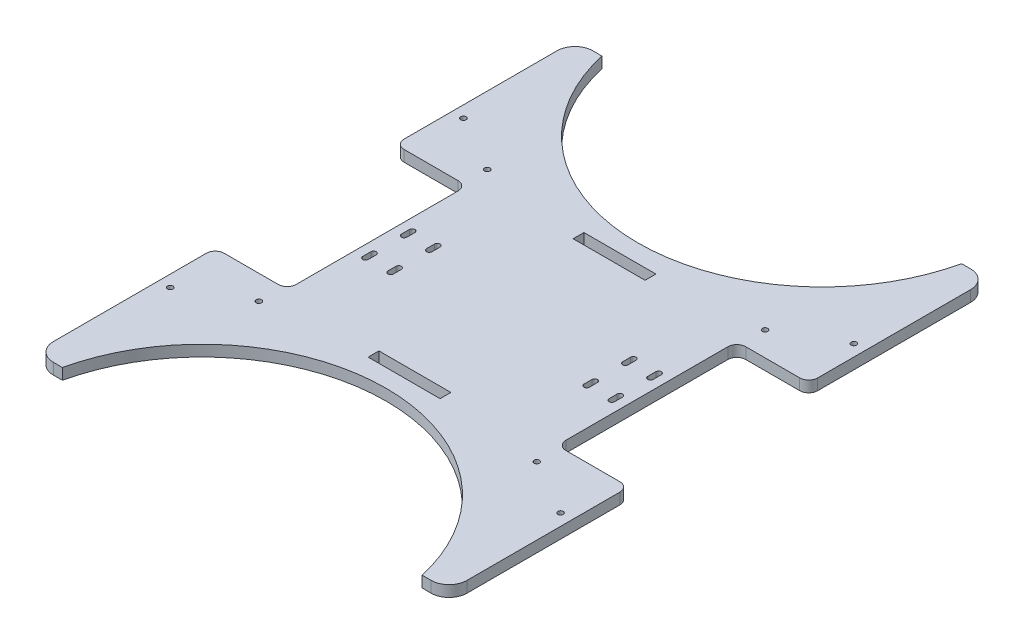
from build123d import *

# Parameters (mm, degrees)
EXTRUDE_1_DEPTH          = 6.18
CUT_EXTRUDE_1_DEPTH      = 7.18
FILLET_2_R               = 5
FILLET_3_R               = 5
FILLET_4_R               = 5
FILLET_5_R               = 5
SKETCH_4_W               = 40
SKETCH_4_H               = 6
SKETCH_4_R               = 1.5
CUT_EXTRUDE_2_DEPTH      = 7.18
CUT_EXTRUDE_9_DEPTH      = 1
CUT_EXTRUDE_9_DEPTH_BACK = 7.18


with BuildPart() as part:
    # 草图1 → 凸台-拉伸1 (new body)
    with BuildSketch(Plane(origin=(0, 0, 0), x_dir=(1, 0, 0), z_dir=(0, 1, 0))):
        with BuildLine():
            Line((18.586012984, 33.22179039), (228.586012984, 33.22179039))
            ThreePointArc((228.586012984, 33.22179039), (235.657080796, 30.292858202), (238.586012984, 23.22179039))
            Line((238.586012984, 23.22179039), (238.586012984, -256.77820961))
            ThreePointArc((238.586012984, -256.77820961), (235.657080796, -263.849277422), (228.586012984, -266.77820961))
            Line((228.586012984, -266.77820961), (18.586012984, -266.77820961))
            ThreePointArc((18.586012984, -266.77820961), (11.514945172, -263.849277422), (8.586012984, -256.77820961))
            Line((8.586012984, -256.77820961), (8.586012984, 23.22179039))
            ThreePointArc((8.586012984, 23.22179039), (11.514945172, 30.292858202), (18.586012984, 33.22179039))
        make_face()
    extrude(amount=EXTRUDE_1_DEPTH)

    # 草图2 → 切除-拉伸1 (cut, through all)
    with BuildSketch(Plane(origin=(0, 6.18, 0), x_dir=(1, 0, 0), z_dir=(0, 1, 0))):
        with BuildLine():
            Line((48.586012984, -161.77820961), (48.586012984, -71.77820961))
            ThreePointArc((48.586012984, -71.77820961), (47.12154689, -68.242675704), (43.586012984, -66.77820961))
            Line((43.586012984, -66.77820961), (8.586012984, -66.77820961))
            Line((8.586012984, -66.77820961), (8.586012984, -166.77820961))
            Line((8.586012984, -166.77820961), (43.586012984, -166.77820961))
            ThreePointArc((43.586012984, -166.77820961), (47.12154689, -165.313743516), (48.586012984, -161.77820961))
        make_face()
        with BuildLine():
            Line((56.586012984, -103.77820961), (56.586012984, -108.27820961))
            ThreePointArc((56.586012984, -108.27820961), (55.086012984, -109.77820961), (53.586012984, -108.27820961))
            Line((53.586012984, -108.27820961), (53.586012984, -103.77820961))
            ThreePointArc((53.586012984, -103.77820961), (55.086012984, -102.27820961), (56.586012984, -103.77820961))
        make_face()
        with BuildLine():
            Line((70.586012984, -103.77820961), (70.586012984, -108.27820961))
            ThreePointArc((70.586012984, -108.27820961), (69.086012984, -109.77820961), (67.586012984, -108.27820961))
            Line((67.586012984, -108.27820961), (67.586012984, -103.77820961))
            ThreePointArc((67.586012984, -103.77820961), (69.086012984, -102.27820961), (70.586012984, -103.77820961))
        make_face()
        with BuildLine():
            Line((70.586012984, -129.77820961), (70.586012984, -125.27820961))
            ThreePointArc((70.586012984, -125.27820961), (69.086012984, -123.77820961), (67.586012984, -125.27820961))
            Line((67.586012984, -125.27820961), (67.586012984, -129.77820961))
            ThreePointArc((67.586012984, -129.77820961), (69.086012984, -131.27820961), (70.586012984, -129.77820961))
        make_face()
        with BuildLine():
            Line((56.586012984, -129.77820961), (56.586012984, -125.27820961))
            ThreePointArc((56.586012984, -125.27820961), (55.086012984, -123.77820961), (53.586012984, -125.27820961))
            Line((53.586012984, -125.27820961), (53.586012984, -129.77820961))
            ThreePointArc((53.586012984, -129.77820961), (55.086012984, -131.27820961), (56.586012984, -129.77820961))
        make_face()
        with BuildLine():
            Line((176.586012984, -129.77820961), (176.586012984, -125.27820961))
            ThreePointArc((176.586012984, -125.27820961), (178.086012984, -123.77820961), (179.586012984, -125.27820961))
            Line((179.586012984, -125.27820961), (179.586012984, -129.77820961))
            ThreePointArc((179.586012984, -129.77820961), (178.086012984, -131.27820961), (176.586012984, -129.77820961))
        make_face()
        with BuildLine():
            Line((190.586012984, -129.77820961), (190.586012984, -125.27820961))
            ThreePointArc((190.586012984, -125.27820961), (192.086012984, -123.77820961), (193.586012984, -125.27820961))
            Line((193.586012984, -125.27820961), (193.586012984, -129.77820961))
            ThreePointArc((193.586012984, -129.77820961), (192.086012984, -131.27820961), (190.586012984, -129.77820961))
        make_face()
        with BuildLine():
            Line((190.586012984, -103.77820961), (190.586012984, -108.27820961))
            ThreePointArc((190.586012984, -108.27820961), (192.086012984, -109.77820961), (193.586012984, -108.27820961))
            Line((193.586012984, -108.27820961), (193.586012984, -103.77820961))
            ThreePointArc((193.586012984, -103.77820961), (192.086012984, -102.27820961), (190.586012984, -103.77820961))
        make_face()
        with BuildLine():
            Line((176.586012984, -103.77820961), (176.586012984, -108.27820961))
            ThreePointArc((176.586012984, -108.27820961), (178.086012984, -109.77820961), (179.586012984, -108.27820961))
            Line((179.586012984, -108.27820961), (179.586012984, -103.77820961))
            ThreePointArc((179.586012984, -103.77820961), (178.086012984, -102.27820961), (176.586012984, -103.77820961))
        make_face()
        with BuildLine():
            Line((198.586012984, -161.77820961), (198.586012984, -71.77820961))
            ThreePointArc((198.586012984, -71.77820961), (200.050479078, -68.242675704), (203.586012984, -66.77820961))
            Line((203.586012984, -66.77820961), (238.586012984, -66.77820961))
            Line((238.586012984, -66.77820961), (238.586012984, -166.77820961))
            Line((238.586012984, -166.77820961), (203.586012984, -166.77820961))
            ThreePointArc((203.586012984, -166.77820961), (200.050479078, -165.313743516), (198.586012984, -161.77820961))
        make_face()
    extrude(amount=-CUT_EXTRUDE_1_DEPTH, mode=Mode.SUBTRACT)

    # 圆角2
    fillet_2_edges = [part.edges().sort_by_distance(p)[0] for p in [
        (8.586012984, 3.09, 66.77820961),
    ]]
    fillet(fillet_2_edges, radius=FILLET_2_R)

    # 圆角3
    fillet_3_edges = [part.edges().sort_by_distance(p)[0] for p in [
        (8.586012984, 3.09, 166.77820961),
    ]]
    fillet(fillet_3_edges, radius=FILLET_3_R)

    # 圆角4
    fillet_4_edges = [part.edges().sort_by_distance(p)[0] for p in [
        (238.586012984, 3.09, 166.77820961),
    ]]
    fillet(fillet_4_edges, radius=FILLET_4_R)

    # 圆角5
    fillet_5_edges = [part.edges().sort_by_distance(p)[0] for p in [
        (238.586012984, 3.09, 66.77820961),
    ]]
    fillet(fillet_5_edges, radius=FILLET_5_R)

    # 草图4 → 切除-拉伸2 (cut, through all)
    with BuildSketch(Plane(origin=(0, 0, 0), x_dir=(-1, 0, 0), z_dir=(0, -1, 0))):
        with Locations((-123.586012984, -59.77820961)):
            Rectangle(SKETCH_4_W, SKETCH_4_H)
        with Locations((-123.586012984, -173.77820961)):
            Rectangle(SKETCH_4_W, SKETCH_4_H)
        with Locations((-232.113924071, -35.249657434)):
            Circle(SKETCH_4_R)
        with Locations((-200.838101897, -53.306761785)):
            Circle(SKETCH_4_R)
        with Locations((-232.113924071, -198.306761785)):
            Circle(SKETCH_4_R)
        with Locations((-200.838101897, -180.249657434)):
            Circle(SKETCH_4_R)
        with Locations((-15.058101897, -198.306761785)):
            Circle(SKETCH_4_R)
        with Locations((-46.333924071, -180.249657434)):
            Circle(SKETCH_4_R)
        with Locations((-46.333924071, -53.306761785)):
            Circle(SKETCH_4_R)
        with Locations((-15.058101897, -35.249657434)):
            Circle(SKETCH_4_R)
    extrude(amount=-CUT_EXTRUDE_2_DEPTH, mode=Mode.SUBTRACT)

    # 草图5 → 切除-拉伸9 (cut, two sides)
    with BuildSketch(Plane(origin=(0, 6.18, 0), x_dir=(1, 0, 0), z_dir=(0, 1, 0))) as cut_extrude_9_sk:
        with BuildLine():
            Line((123.586012984, -266.77820961), (23.586012984, -266.77820961))
            ThreePointArc((23.586012984, -266.77820961), (123.586012984, -186.77820961), (223.586012984, -266.77820961))
            Line((223.586012984, -266.77820961), (123.586012984, -266.77820961))
        make_face()
        with BuildLine():
            Line((23.586012984, 33.22179039), (223.586012984, 33.22179039))
            ThreePointArc((223.586012984, 33.22179039), (123.586012984, -46.77820961), (23.586012984, 33.22179039))
        make_face()
    extrude(amount=CUT_EXTRUDE_9_DEPTH, mode=Mode.SUBTRACT)
    extrude(cut_extrude_9_sk.sketch, amount=-CUT_EXTRUDE_9_DEPTH_BACK, mode=Mode.SUBTRACT)


solid = part.part
